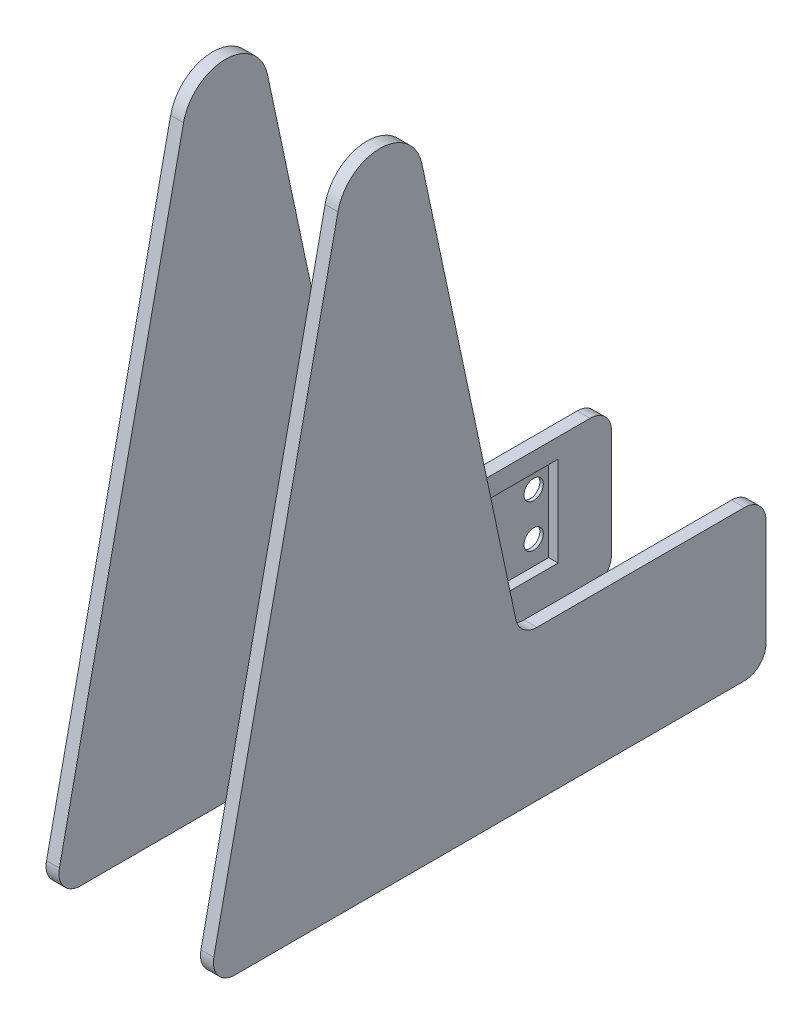
from build123d import *

# Parameters (mm, degrees)
BOSS_EXTRUDE1_DEPTH           = 3
SKETCH6_W                     = 55.5
SKETCH6_H                     = 20.98660254
CUT_EXTRUDE1_DEPTH            = 2.2
SKETCH12_W                    = 2.25
SKETCH12_H                    = 0.8
M4_CLEARANCE_HOLE1_AT_2_COUNT = 2
M4_CLEARANCE_HOLE1_AT_2_PITCH = 48.5
M4_CLEARANCE_HOLE1_AT_3_COUNT = 2
M4_CLEARANCE_HOLE1_AT_3_PITCH = 49.520197899
M4_CLEARANCE_HOLE1_AT_4_COUNT = 2
M4_CLEARANCE_HOLE1_AT_4_PITCH = 10


with BuildPart() as part:
    # Sketch3 → Boss-Extrude1 (new body)
    with BuildSketch(Plane(origin=(16.5, 0, 0), x_dir=(0, 0, -1), z_dir=(1, 0, 0))):
        with BuildLine():
            ThreePointArc((-9.781214465, 142.08034699), (0, 150), (9.781214465, 142.08034699))
            Line((9.781214465, 142.08034699), (31.71371223, 38.959826505))
            ThreePointArc((31.71371223, 38.959826505), (33.457961844, 36.114072345), (36.604319462, 35))
            Line((36.604319462, 35), (85, 35))
            ThreePointArc((85, 35), (88.535533906, 33.535533906), (90, 30))
            Line((90, 30), (90, 5))
            ThreePointArc((90, 5), (88.535533906, 1.464466094), (85, 0))
            Line((85, 0), (0, 0))
            Line((0, 0), (-33.824720318, 0))
            ThreePointArc((-33.824720318, 0), (-37.710647973, 1.853642382), (-38.71532755, 6.040173495))
            Line((-38.71532755, 6.040173495), (-9.781214465, 142.08034699))
        make_face()
    extrude(amount=BOSS_EXTRUDE1_DEPTH)


with BuildPart() as body_2:
    # Mirror2: mirrored copy
    add(part.part.mirror(Plane(origin=(0, 0, 0), x_dir=(0, 0, 1), z_dir=(1, 0, 0))))

    # Sketch6 → Cut-Extrude1 (cut)
    with BuildSketch(Plane.ZY.offset(18.7)):
        with Locations((-49.8, 19.99330127)):
            Rectangle(SKETCH6_W, SKETCH6_H)
    extrude(amount=-CUT_EXTRUDE1_DEPTH, mode=Mode.SUBTRACT)

    # Sketch12 → M4 Clearance Hole1 (revolve, cut)
    with BuildSketch(Plane(origin=(-18.7, 15, -25.55), x_dir=(0, 0, -1), z_dir=(0, 1, 0))):
        with Locations((1.125, 0.4)):
            Rectangle(SKETCH12_W, SKETCH12_H)
    m4_clearance_hole1 = revolve(axis=Axis((-12.35, 15, -25.55), (-1, 0, 0)), mode=Mode.SUBTRACT)

    # M4 Clearance Hole1 at 2: M4 Clearance Hole1 ×2
    with Locations(*[(0, 0, -i * M4_CLEARANCE_HOLE1_AT_2_PITCH) for i in range(1, M4_CLEARANCE_HOLE1_AT_2_COUNT)]):
        add(m4_clearance_hole1, mode=Mode.SUBTRACT)

    # M4 Clearance Hole1 at 3: M4 Clearance Hole1 ×2
    with Locations(*[Vector(0, 0.201937804, -0.979398348) * (i * M4_CLEARANCE_HOLE1_AT_3_PITCH) for i in range(1, M4_CLEARANCE_HOLE1_AT_3_COUNT)]):
        add(m4_clearance_hole1, mode=Mode.SUBTRACT)

    # M4 Clearance Hole1 at 4: M4 Clearance Hole1 ×2
    with Locations(*[(0, i * M4_CLEARANCE_HOLE1_AT_4_PITCH, 0) for i in range(1, M4_CLEARANCE_HOLE1_AT_4_COUNT)]):
        add(m4_clearance_hole1, mode=Mode.SUBTRACT)


solid = Compound([part.part, body_2.part])
